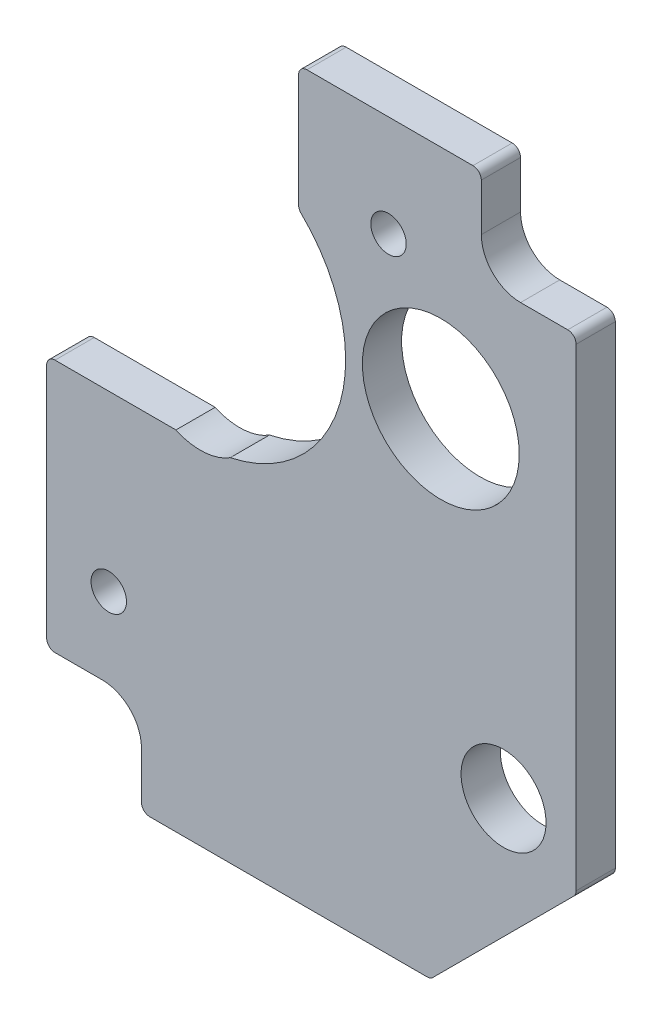
from build123d import *

# Parameters (mm, degrees)
BOSS_EXTRUDE1_DEPTH              = 4.7625
F_6_CLEARANCE_HOLE1_D            = 4.3053
F_3_4_0_75_DIAMETER_HOLE1_D      = 19.05
F_13_32_0_40625_DIAMETER_HOLE1_D = 10.31875


with BuildPart() as part:
    # Sketch1 → Boss-Extrude1 (new body)
    with BuildSketch(Plane.XY):
        with BuildLine():
            Line((-17.78404549, -88.20554549), (-0.69445451, -71.11595451))
            ThreePointArc((-0.69445451, -71.11595451), (-0.474213395, -70.786340388), (-0.396875, -70.397534021))
            Line((-0.396875, -70.397534021), (-0.396875, -12.92225))
            ThreePointArc((-0.396875, -12.92225), (-0.69445451, -12.20382951), (-1.412875, -11.90625))
            Line((-1.412875, -11.90625), (-7.14375, -11.90625))
            ThreePointArc((-7.14375, -11.90625), (-10.511346045, -10.511346045), (-11.90625, -7.14375))
            Line((-11.90625, -7.14375), (-11.90625, -1.412875))
            ThreePointArc((-11.90625, -1.412875), (-12.20382951, -0.69445451), (-12.92225, -0.396875))
            Line((-12.92225, -0.396875), (-33.0835, -0.396875))
            ThreePointArc((-33.0835, -0.396875), (-33.80192049, -0.69445451), (-34.0995, -1.412875))
            Line((-34.0995, -1.412875), (-34.0995, -15.131583582))
            ThreePointArc((-34.0995, -15.131583582), (-34.01851745, -15.529073666), (-33.788479592, -15.863198081))
            ThreePointArc((-33.788479592, -15.863198081), (-29.070029057, -33.446687471), (-42.397902867, -45.848729815))
            add(Edge.make_bspline(
                [(-42.397902867, -45.848729815), (-45.551783199, -47.860753205), (-48.991026243, -46.228)],
                knots=[-2.210610991, -2.210610991, -2.210610991, -1.065002144, -1.065002144, -1.065002144], degree=2, weights=[1, 0.84038431, 1]))
            Line((-48.991026243, -46.228), (-63.674625, -46.228))
            ThreePointArc((-63.674625, -46.228), (-64.39304549, -46.52557951), (-64.690625, -47.244))
            Line((-64.690625, -47.244), (-64.690625, -75.97775))
            ThreePointArc((-64.690625, -75.97775), (-64.39304549, -76.69617049), (-63.674625, -76.99375))
            Line((-63.674625, -76.99375), (-57.94375, -76.99375))
            ThreePointArc((-57.94375, -76.99375), (-54.576153955, -78.388653955), (-53.18125, -81.75625))
            Line((-53.18125, -81.75625), (-53.18125, -87.487125))
            ThreePointArc((-53.18125, -87.487125), (-52.88367049, -88.20554549), (-52.16525, -88.503125))
            Line((-52.16525, -88.503125), (-18.502465979, -88.503125))
            ThreePointArc((-18.502465979, -88.503125), (-18.113659612, -88.425786605), (-17.78404549, -88.20554549))
        make_face()
    extrude(amount=BOSS_EXTRUDE1_DEPTH)

    # #6 Clearance Hole1 (through all)
    with Locations(Plane.XY.offset(4.7625)):
        with Locations((-57.15, -67.31), (-23.1775, -12.7)):
            Hole(F_6_CLEARANCE_HOLE1_D / 2)

    # 3/4 (0.75) Diameter Hole1 (through all)
    with Locations(Plane.XY.offset(4.7625)):
        with Locations((-16.8275, -27.94)):
            Hole(F_3_4_0_75_DIAMETER_HOLE1_D / 2)

    # 13/32 (0.40625) Diameter Hole1 (through all)
    with Locations(Plane.XY.offset(4.7625)):
        with Locations((-9.2075, -65.0875)):
            Hole(F_13_32_0_40625_DIAMETER_HOLE1_D / 2)


solid = part.part
